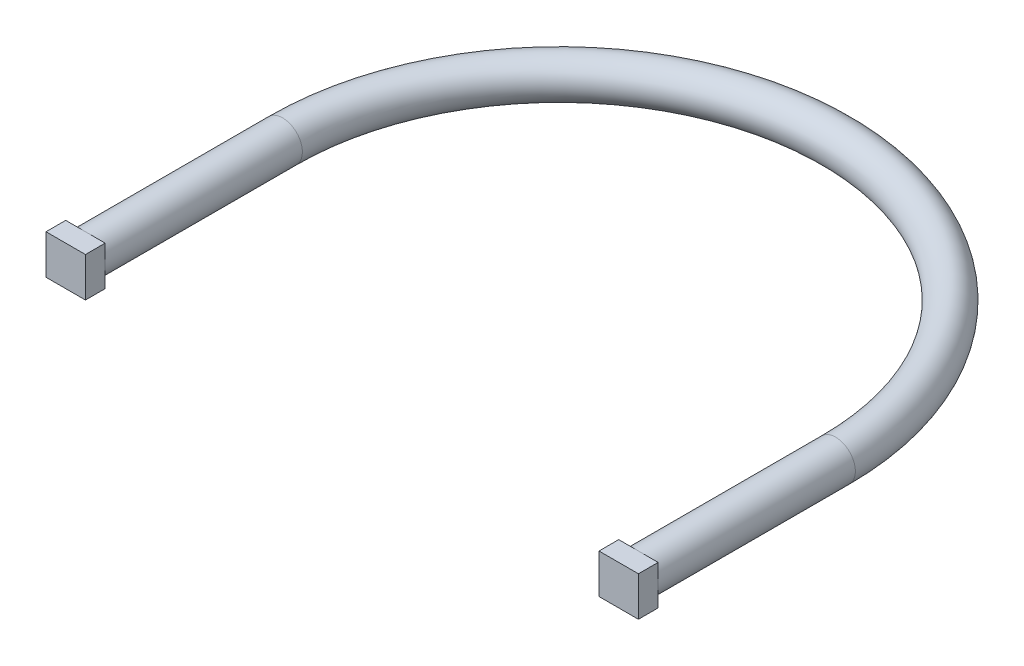
from build123d import *

# Parameters (mm, degrees)
SKETCH6_R           = 5
SKETCH8_W           = 10
SKETCH8_H           = 10
BOSS_EXTRUDE1_DEPTH = 5
SKETCH9_W           = 10
SKETCH9_H           = 10
BOSS_EXTRUDE2_DEPTH = 5


with BuildPart() as part:
    # Sweep1: sweep along a path in Sketch7
    with BuildLine(Plane(origin=(0, 0, 0), x_dir=(1, 0, 0), z_dir=(0, 1, 0))) as sweep1_path:
        Line((0, 0), (0, 50))
        ThreePointArc((0, 50), (70.1, 120.1), (140.2, 50))
        Line((140.2, 50), (140.2, 0))
    # Sketch6 → Sweep1 (sweep)
    with BuildSketch(Plane.XY):
        Circle(SKETCH6_R)
    sweep(path=sweep1_path.line)

    # Sketch8 → Boss-Extrude1 (add)
    with BuildSketch(Plane.XY):
        Rectangle(SKETCH8_W, SKETCH8_H)
    extrude(amount=BOSS_EXTRUDE1_DEPTH)

    # Sketch9 → Boss-Extrude2 (add)
    with BuildSketch(Plane.XY):
        with Locations((140.2, 0)):
            Rectangle(SKETCH9_W, SKETCH9_H)
    extrude(amount=BOSS_EXTRUDE2_DEPTH)


solid = part.part
